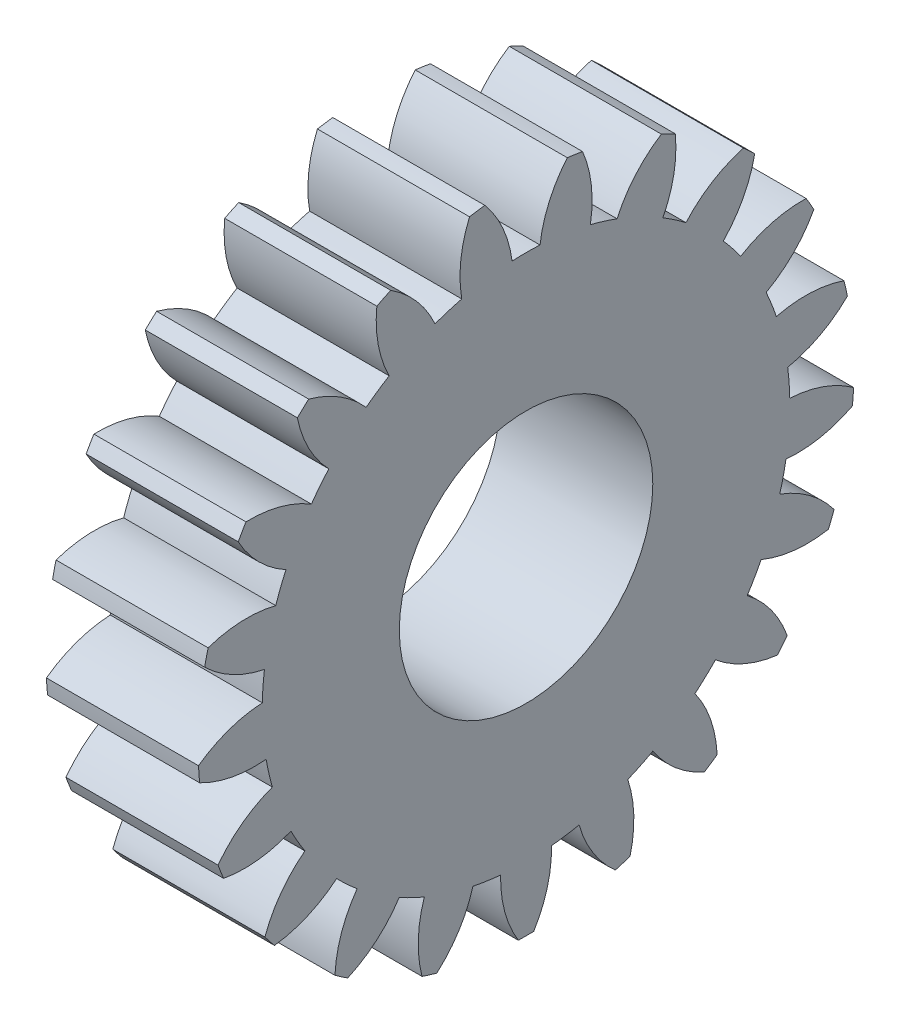
from build123d import *

# Parameters (mm, degrees)
BASPROSKE_W     = 12
BASPROSKE_H     = 25.875
TOOTHCUT_DEPTH  = 39.510144767
TEETHCUTS_COUNT = 21
TEETHCUTS_ANGLE = 342.857142857
BORSKE_R        = 10
BORE_DEPTH      = 50.0000508


with BuildPart() as part:
    # BasProSke → Base-Revolve (revolve)
    with BuildSketch(Plane(origin=(0, 0, 0), x_dir=(1, 0, 0), z_dir=(0, 1, 0)), mode=Mode.PRIVATE) as base_revolve_sk:
        with Locations((6, 12.9375)):
            Rectangle(BASPROSKE_W, BASPROSKE_H)
    revolve(base_revolve_sk.sketch.rotate(Axis((-10, 0, 0), (1, 0, 0)), 180), axis=Axis((-10, 0, 0), (1, 0, 0)))

    # TooCutSke → ToothCut (cut, through all)
    with BuildSketch(Plane(origin=(0, 0, 0), x_dir=(0, 0, -1), z_dir=(1, 0, 0))):
        with BuildLine():
            ThreePointArc((1.101400125, 20.782335047), (0, 20.8115), (-1.101400125, 20.782335047))
            ThreePointArc((-1.101400125, 20.782335047), (-1.83071474, 23.395008735), (-3.272169586, 25.692871119))
            ThreePointArc((-3.272169586, 25.692871119), (0, 25.9004), (3.272169586, 25.692871119))
            ThreePointArc((3.272169586, 25.692871119), (1.83071474, 23.395008735), (1.101400125, 20.782335047))
        make_face()
    toothcut = extrude(amount=TOOTHCUT_DEPTH, mode=Mode.SUBTRACT)

    # TeethCuts: ToothCut ×21 about axis
    teethcuts_axis = Axis((-10, 0, 0), (1, 0, 0))
    for i in range(1, TEETHCUTS_COUNT):
        add(toothcut.rotate(teethcuts_axis, i * TEETHCUTS_ANGLE / (TEETHCUTS_COUNT - 1)), mode=Mode.SUBTRACT)

    # BorSke → Bore (cut, symmetric)
    with BuildSketch(Plane(origin=(0, 0, 0), x_dir=(0, 0, -1), z_dir=(1, 0, 0))):
        with Locations(Location((0, 0, 0), (0, 0, 180))):
            Circle(BORSKE_R)
    extrude(amount=BORE_DEPTH, both=True, mode=Mode.SUBTRACT)


solid = part.part
